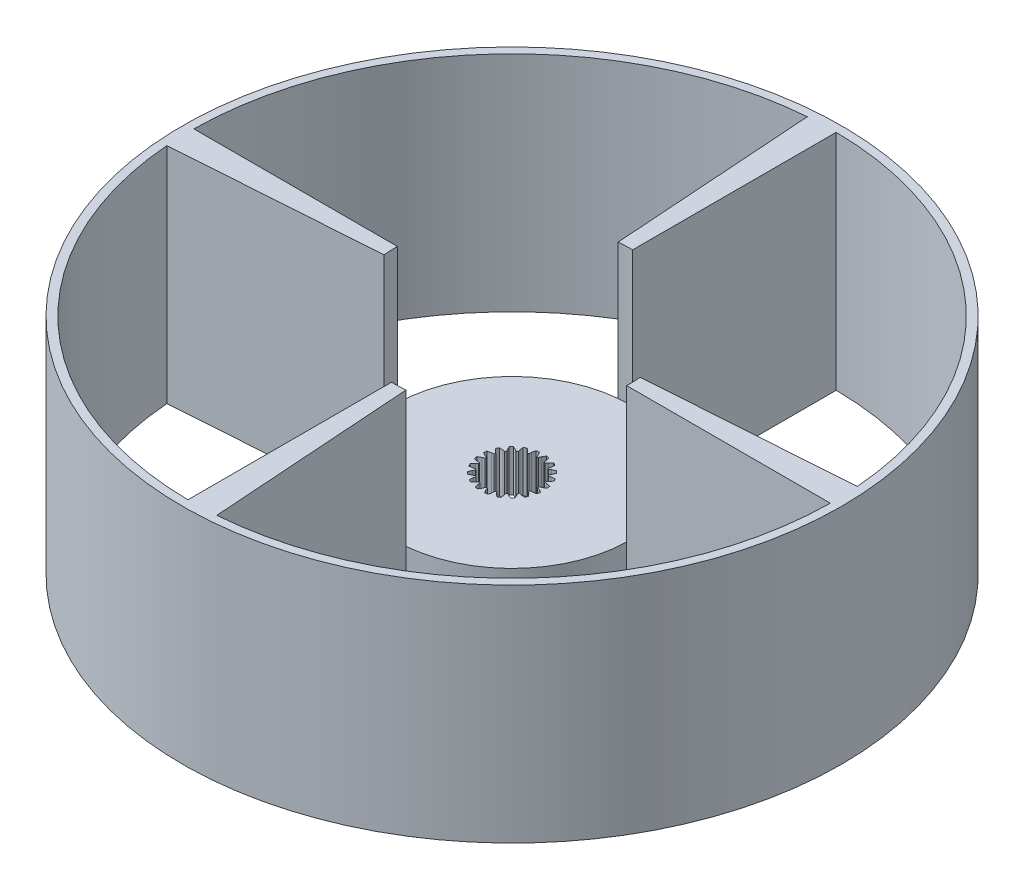
from build123d import *

# Parameters (mm, degrees)
IZIM1_R                      = 118
IZIM1_R_2                    = 115
EKSTR_ZYON_NCE1_DEPTH        = 80
Y_KSEKLIK_EKSTR_ZYON4_START  = -15
IZIM4_R                      = 42.097182255
Y_KSEKLIK_EKSTR_ZYON4_DEPTH  = 15
Y_KSEKLIK_EKSTR_ZYON5_DEPTH  = 80
Y_KSEKLIK_EKSTR_ZYON11_DEPTH = 3


with BuildPart() as part:
    # Çizim1 → Ekstrüzyon-İnce1 (new body)
    with BuildSketch(Plane(origin=(0, 0, 0), x_dir=(1, 0, 0), z_dir=(0, 1, 0))):
        Circle(IZIM1_R)
        Circle(IZIM1_R_2, mode=Mode.SUBTRACT)
    extrude(amount=EKSTR_ZYON_NCE1_DEPTH)



with BuildPart() as body_2:
    # Çizim4 → Yükseklik-Ekstrüzyon4 (new body)
    with BuildSketch(Plane(origin=(0, 16.5, 0), x_dir=(-1, 0, 0), z_dir=(0, -1, 0)).offset(Y_KSEKLIK_EKSTR_ZYON4_START)):
        Circle(IZIM4_R)
        with BuildLine():
            Line((-1.413507528, -11.211244198), (-0.717346024, -10.084731354))
            Line((-0.717346024, -10.084731354), (-0.413803631, -9.29078934))
            ThreePointArc((-0.413803631, -9.29078934), (-0.149812681, -9.298793264), (0.114299095, -9.299297593))
            Line((0.114299095, -9.299297593), (0.392108221, -10.10260575))
            Line((0.392108221, -10.10260575), (1.051619387, -11.250959811))
            ThreePointArc((1.051619387, -11.250959811), (1.587690718, -11.187905889), (2.12013944, -11.099324698))
            Line((2.12013944, -11.099324698), (2.434116761, -9.812821582))
            Line((2.434116761, -9.812821582), (2.477461157, -8.963938097))
            ThreePointArc((2.477461157, -8.963938097), (2.731004819, -8.889972592), (2.982345891, -8.80883721))
            Line((2.982345891, -8.80883721), (3.494793943, -9.486980926))
            Line((3.494793943, -9.486980926), (4.476887256, -10.37533038))
            ThreePointArc((4.476887256, -10.37533038), (4.967236655, -10.149707386), (5.446252388, -9.900925963))
            Line((5.446252388, -9.900925963), (5.347311239, -8.580364463))
            Line((5.347311239, -8.580364463), (5.126214786, -7.759634139))
            ThreePointArc((5.126214786, -7.759634139), (5.34449254, -7.610939462), (5.558459892, -7.456106466))
            Line((5.558459892, -7.456106466), (6.255384884, -7.94270431))
            Line((6.255384884, -7.94270431), (7.463926207, -8.484091323))
            ThreePointArc((7.463926207, -8.484091323), (7.860554858, -8.117984806), (8.239248205, -7.733355611))
            Line((8.239248205, -7.733355611), (7.737073635, -6.508001488))
            Line((7.737073635, -6.508001488), (7.273178795, -5.795763126))
            ThreePointArc((7.273178795, -5.795763126), (7.434824093, -5.586894549), (7.590473111, -5.373520071))
            Line((7.590473111, -5.373520071), (8.403655169, -5.620940455))
            Line((8.403655169, -5.620940455), (9.720344057, -5.762370295))
            ThreePointArc((9.720344057, -5.762370295), (9.984427185, -5.291617313), (10.225729002, -4.808790531))
            Line((10.225729002, -4.808790531), (9.369477357, -3.798589983))
            Line((9.369477357, -3.798589983), (8.708193389, -3.264562437))
            ThreePointArc((8.708193389, -3.264562437), (8.797383263, -3.015965472), (8.879477935, -2.764936093))
            Line((8.879477935, -2.764936093), (9.729317134, -2.748959786))
            Line((9.729317134, -2.748959786), (11.025266905, -2.476588314))
            ThreePointArc((11.025266905, -2.476588314), (11.130954213, -1.947269448), (11.211244198, -1.413507528))
            Line((11.211244198, -1.413507528), (10.084731354, -0.717346024))
            Line((10.084731354, -0.717346024), (9.29078934, -0.413803631))
            ThreePointArc((9.29078934, -0.413803631), (9.298793264, -0.149812681), (9.299297593, 0.114299095))
            Line((9.299297593, 0.114299095), (10.10260575, 0.392108221))
            Line((10.10260575, 0.392108221), (11.250959811, 1.051619387))
            ThreePointArc((11.250959811, 1.051619387), (11.187905889, 1.587690718), (11.099324698, 2.12013944))
            Line((11.099324698, 2.12013944), (9.812821582, 2.434116761))
            Line((9.812821582, 2.434116761), (8.963938097, 2.477461157))
            ThreePointArc((8.963938097, 2.477461157), (8.889972592, 2.731004819), (8.80883721, 2.982345891))
            Line((8.80883721, 2.982345891), (9.486980926, 3.494793943))
            Line((9.486980926, 3.494793943), (10.37533038, 4.476887256))
            ThreePointArc((10.37533038, 4.476887256), (10.149707386, 4.967236655), (9.900925963, 5.446252388))
            Line((9.900925963, 5.446252388), (8.580364463, 5.347311239))
            Line((8.580364463, 5.347311239), (7.759634139, 5.126214786))
            ThreePointArc((7.759634139, 5.126214786), (7.610939462, 5.34449254), (7.456106466, 5.558459892))
            Line((7.456106466, 5.558459892), (7.94270431, 6.255384884))
            Line((7.94270431, 6.255384884), (8.484091323, 7.463926207))
            ThreePointArc((8.484091323, 7.463926207), (8.117984806, 7.860554858), (7.733355611, 8.239248205))
            Line((7.733355611, 8.239248205), (6.508001488, 7.737073635))
            Line((6.508001488, 7.737073635), (5.795763126, 7.273178795))
            ThreePointArc((5.795763126, 7.273178795), (5.586894549, 7.434824093), (5.373520071, 7.590473111))
            Line((5.373520071, 7.590473111), (5.620940455, 8.403655169))
            Line((5.620940455, 8.403655169), (5.762370295, 9.720344057))
            ThreePointArc((5.762370295, 9.720344057), (5.291617313, 9.984427185), (4.808790531, 10.225729002))
            Line((4.808790531, 10.225729002), (3.798589983, 9.369477357))
            Line((3.798589983, 9.369477357), (3.264562437, 8.708193389))
            ThreePointArc((3.264562437, 8.708193389), (3.015965472, 8.797383263), (2.764936093, 8.879477935))
            Line((2.764936093, 8.879477935), (2.748959786, 9.729317134))
            Line((2.748959786, 9.729317134), (2.476588314, 11.025266905))
            ThreePointArc((2.476588314, 11.025266905), (1.947269448, 11.130954213), (1.413507528, 11.211244198))
            Line((1.413507528, 11.211244198), (0.717346024, 10.084731354))
            Line((0.717346024, 10.084731354), (0.413803631, 9.29078934))
            ThreePointArc((0.413803631, 9.29078934), (0.149812681, 9.298793264), (-0.114299095, 9.299297593))
            Line((-0.114299095, 9.299297593), (-0.392108221, 10.10260575))
            Line((-0.392108221, 10.10260575), (-1.051619387, 11.250959811))
            ThreePointArc((-1.051619387, 11.250959811), (-1.587690718, 11.187905889), (-2.12013944, 11.099324698))
            Line((-2.12013944, 11.099324698), (-2.434116761, 9.812821582))
            Line((-2.434116761, 9.812821582), (-2.477461157, 8.963938097))
            ThreePointArc((-2.477461157, 8.963938097), (-2.731004819, 8.889972592), (-2.982345891, 8.80883721))
            Line((-2.982345891, 8.80883721), (-3.494793943, 9.486980926))
            Line((-3.494793943, 9.486980926), (-4.476887256, 10.37533038))
            ThreePointArc((-4.476887256, 10.37533038), (-4.967236655, 10.149707386), (-5.446252388, 9.900925963))
            Line((-5.446252388, 9.900925963), (-5.347311239, 8.580364463))
            Line((-5.347311239, 8.580364463), (-5.126214786, 7.759634139))
            ThreePointArc((-5.126214786, 7.759634139), (-5.34449254, 7.610939462), (-5.558459892, 7.456106466))
            Line((-5.558459892, 7.456106466), (-6.255384884, 7.94270431))
            Line((-6.255384884, 7.94270431), (-7.463926207, 8.484091323))
            ThreePointArc((-7.463926207, 8.484091323), (-7.860554858, 8.117984806), (-8.239248205, 7.733355611))
            Line((-8.239248205, 7.733355611), (-7.737073635, 6.508001488))
            Line((-7.737073635, 6.508001488), (-7.273178795, 5.795763126))
            ThreePointArc((-7.273178795, 5.795763126), (-7.434824093, 5.586894549), (-7.590473111, 5.373520071))
            Line((-7.590473111, 5.373520071), (-8.403655169, 5.620940455))
            Line((-8.403655169, 5.620940455), (-9.720344057, 5.762370295))
            ThreePointArc((-9.720344057, 5.762370295), (-9.984427185, 5.291617313), (-10.225729002, 4.808790531))
            Line((-10.225729002, 4.808790531), (-9.369477357, 3.798589983))
            Line((-9.369477357, 3.798589983), (-8.708193389, 3.264562437))
            ThreePointArc((-8.708193389, 3.264562437), (-8.797383263, 3.015965472), (-8.879477935, 2.764936093))
            Line((-8.879477935, 2.764936093), (-9.729317134, 2.748959786))
            Line((-9.729317134, 2.748959786), (-11.025266905, 2.476588314))
            ThreePointArc((-11.025266905, 2.476588314), (-11.130954213, 1.947269448), (-11.211244198, 1.413507528))
            Line((-11.211244198, 1.413507528), (-10.084731354, 0.717346024))
            Line((-10.084731354, 0.717346024), (-9.29078934, 0.413803631))
            ThreePointArc((-9.29078934, 0.413803631), (-9.298793264, 0.149812681), (-9.299297593, -0.114299095))
            Line((-9.299297593, -0.114299095), (-10.10260575, -0.392108221))
            Line((-10.10260575, -0.392108221), (-11.250959811, -1.051619387))
            ThreePointArc((-11.250959811, -1.051619387), (-11.187905889, -1.587690718), (-11.099324698, -2.12013944))
            Line((-11.099324698, -2.12013944), (-9.812821582, -2.434116761))
            Line((-9.812821582, -2.434116761), (-8.963938097, -2.477461157))
            ThreePointArc((-8.963938097, -2.477461157), (-8.889972592, -2.731004819), (-8.80883721, -2.982345891))
            Line((-8.80883721, -2.982345891), (-9.486980926, -3.494793943))
            Line((-9.486980926, -3.494793943), (-10.37533038, -4.476887256))
            ThreePointArc((-10.37533038, -4.476887256), (-10.149707386, -4.967236655), (-9.900925963, -5.446252388))
            Line((-9.900925963, -5.446252388), (-8.580364463, -5.347311239))
            Line((-8.580364463, -5.347311239), (-7.759634139, -5.126214786))
            ThreePointArc((-7.759634139, -5.126214786), (-7.610939462, -5.34449254), (-7.456106466, -5.558459892))
            Line((-7.456106466, -5.558459892), (-7.94270431, -6.255384884))
            Line((-7.94270431, -6.255384884), (-8.484091323, -7.463926207))
            ThreePointArc((-8.484091323, -7.463926207), (-8.117984806, -7.860554858), (-7.733355611, -8.239248205))
            Line((-7.733355611, -8.239248205), (-6.508001488, -7.737073635))
            Line((-6.508001488, -7.737073635), (-5.795763126, -7.273178795))
            ThreePointArc((-5.795763126, -7.273178795), (-5.586894549, -7.434824093), (-5.373520071, -7.590473111))
            Line((-5.373520071, -7.590473111), (-5.620940455, -8.403655169))
            Line((-5.620940455, -8.403655169), (-5.762370295, -9.720344057))
            ThreePointArc((-5.762370295, -9.720344057), (-5.291617313, -9.984427185), (-4.808790531, -10.225729002))
            Line((-4.808790531, -10.225729002), (-3.798589983, -9.369477357))
            Line((-3.798589983, -9.369477357), (-3.264562437, -8.708193389))
            ThreePointArc((-3.264562437, -8.708193389), (-3.015965472, -8.797383263), (-2.764936093, -8.879477935))
            Line((-2.764936093, -8.879477935), (-2.748959786, -9.729317134))
            Line((-2.748959786, -9.729317134), (-2.476588314, -11.025266905))
            ThreePointArc((-2.476588314, -11.025266905), (-1.947269448, -11.130954213), (-1.413507528, -11.211244198))
        make_face(mode=Mode.SUBTRACT)
    extrude(amount=Y_KSEKLIK_EKSTR_ZYON4_DEPTH)


with BuildPart() as part_1:
    add(part.part)

    add(body_2.part)  # Yükseklik-Ekstrüzyon5 merges body 2
    # Çizim5 → Yükseklik-Ekstrüzyon5 (add)
    with BuildSketch(Plane(origin=(0, 80, 0), x_dir=(1, 0, 0), z_dir=(0, 1, 0))):
        with BuildLine():
            ThreePointArc((-41.912235213, -3.941737337), (-42.072399288, -1.444289413), (-42.083878551, 1.058262663))
            Line((-42.083878551, 1.058262663), (-114.99513068, 1.058262663))
            ThreePointArc((-114.99513068, 1.058262663), (-114.93229853, -3.94547268), (-114.651844003, -8.941737337))
            Line((-114.651844003, -8.941737337), (-41.912235213, -3.941737337))
        make_face()
        with BuildLine():
            Line((8.941737337, -114.651844003), (3.941737337, -41.912235213))
            ThreePointArc((3.941737337, -41.912235213), (1.444289413, -42.072399288), (-1.058262663, -42.083878551))
            Line((-1.058262663, -42.083878551), (-1.058262663, -114.99513068))
            ThreePointArc((-1.058262663, -114.99513068), (3.94547268, -114.93229853), (8.941737337, -114.651844003))
        make_face()
        with BuildLine():
            Line((114.651844003, 8.941737337), (41.912235213, 3.941737337))
            ThreePointArc((41.912235213, 3.941737337), (42.050920075, 1.973036913), (42.097182255, 0))
            ThreePointArc((42.097182255, 0), (42.093856197, -0.529173141), (42.083878551, -1.058262663))
            Line((42.083878551, -1.058262663), (114.99513068, -1.058262663))
            ThreePointArc((114.99513068, -1.058262663), (114.998782664, -0.529136933), (115, 0))
            ThreePointArc((115, 0), (114.912928038, 4.474256341), (114.651844003, 8.941737337))
        make_face()
        with BuildLine():
            ThreePointArc((-3.941737337, 41.912235213), (-1.444289413, 42.072399288), (1.058262663, 42.083878551))
            Line((1.058262663, 42.083878551), (1.058262663, 114.99513068))
            ThreePointArc((1.058262663, 114.99513068), (-3.94547268, 114.93229853), (-8.941737337, 114.651844003))
            Line((-8.941737337, 114.651844003), (-3.941737337, 41.912235213))
        make_face()
    extrude(amount=-Y_KSEKLIK_EKSTR_ZYON5_DEPTH)

    # Çizim6 → Yükseklik-Ekstrüzyon11 (add)
    with BuildSketch(Plane.XZ):
        with BuildLine():
            Line((-42.083878551, -1.058262663), (41.912235213, -3.941737337))
            ThreePointArc((41.912235213, -3.941737337), (42.072399288, -1.444289413), (42.083878551, 1.058262663))
            Line((42.083878551, 1.058262663), (-41.912235213, 3.941737337))
            ThreePointArc((-41.912235213, 3.941737337), (-42.072399288, 1.444289413), (-42.083878551, -1.058262663))
        make_face()
    extrude(amount=-Y_KSEKLIK_EKSTR_ZYON11_DEPTH)


solid = part_1.part
